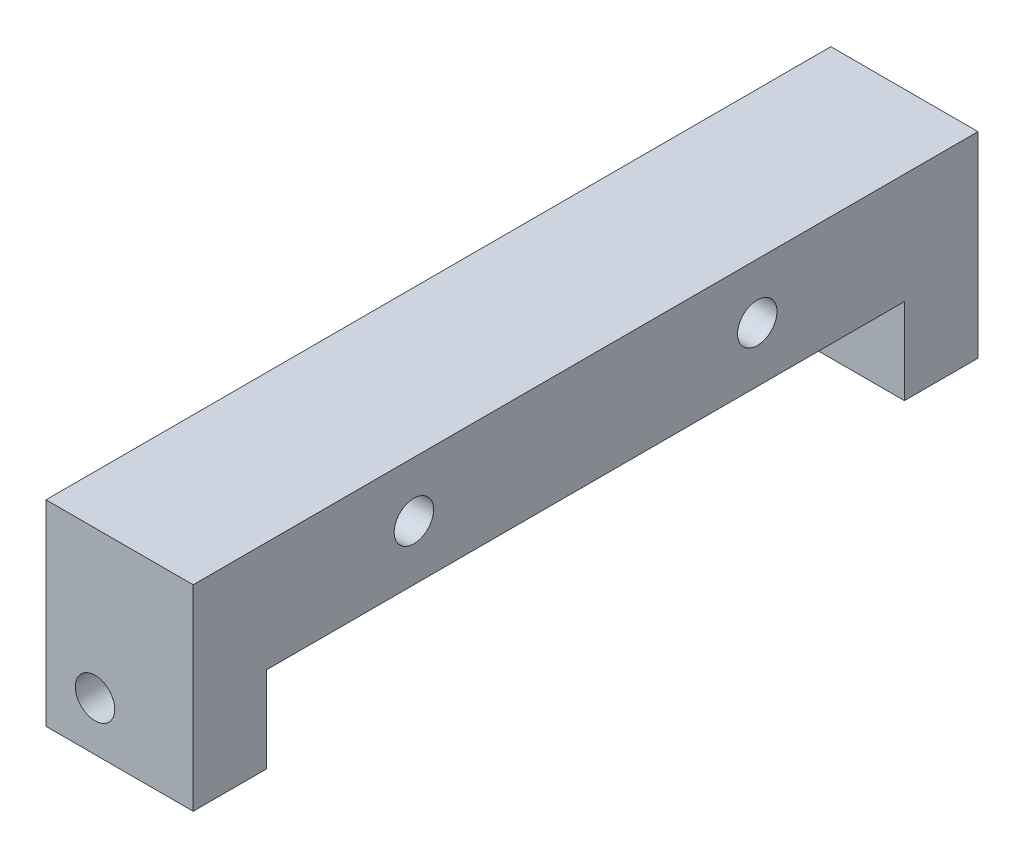
from build123d import *

# Parameters (mm, degrees)
SKETCH1_W                   = 19.05
SKETCH1_H                   = 25.4
EXTRUDE1_DEPTH              = 50.8
CUT_EXTRUDE1_REACH          = 21.05
SKETCH2_W                   = 82.55
SKETCH2_H                   = 11.1125
F_1_4_20_TAPPED_HOLE1_D     = 5.1054
F_1_4_20_TAPPED_HOLE1_DEPTH = 9.525
F_1_4_20_TAPPED_HOLE2_D     = 5.1054
F_1_4_20_TAPPED_HOLE2_DEPTH = 9.525
F_1_4_20_TAPPED_HOLE3_D     = 5.1054
F_1_4_20_TAPPED_HOLE3_DEPTH = 16.51
F_1_4_20_TAPPED_HOLE3_TIP   = 1.533816902
F_1_4_20_TAPPED_HOLE4_D     = 5.1054
F_1_4_20_TAPPED_HOLE4_DEPTH = 19.05


with BuildPart() as part:
    # Sketch1 → Extrude1 (new body, symmetric)
    with BuildSketch(Plane.XY):
        Rectangle(SKETCH1_W, SKETCH1_H)
    extrude(amount=EXTRUDE1_DEPTH, both=True)

    # Sketch2 → Cut-Extrude1 (cut, up to next)
    with BuildSketch(Plane(origin=(9.525, 0, 0), x_dir=(0, 0, -1), z_dir=(1, 0, 0)), mode=Mode.PRIVATE) as cut_extrude1_sk1:
        with Locations((0, -7.14375)):
            Rectangle(SKETCH2_W, SKETCH2_H)
    cut_extrude1_tool1 = extrude(cut_extrude1_sk1.sketch, amount=-CUT_EXTRUDE1_REACH, mode=Mode.PRIVATE) & part.part
    add(cut_extrude1_tool1.solids().sort_by_distance((9.525, -7.14375, 0))[0], mode=Mode.SUBTRACT)

    # 1/4-20 Tapped Hole1
    with Locations(Plane(origin=(0, 0, -50.8), x_dir=(-1, 0, 0), z_dir=(0, 0, -1))):
        with Locations((3.175, -6.35)):
            Hole(F_1_4_20_TAPPED_HOLE1_D / 2, depth=F_1_4_20_TAPPED_HOLE1_DEPTH)

    # 1/4-20 Tapped Hole2
    with Locations(Plane.XY.offset(50.8)):
        with Locations((-3.175, -6.35)):
            Hole(F_1_4_20_TAPPED_HOLE2_D / 2, depth=F_1_4_20_TAPPED_HOLE2_DEPTH)

    # 1/4-20 Tapped Hole3
    with Locations(Plane.XZ.offset(12.7)):
        with Locations((4.7625, 46.0375), (4.7625, -46.0375)):
            Hole(F_1_4_20_TAPPED_HOLE3_D / 2, depth=F_1_4_20_TAPPED_HOLE3_DEPTH)
            with Locations((0, 0, -(F_1_4_20_TAPPED_HOLE3_DEPTH + F_1_4_20_TAPPED_HOLE3_TIP / 2))):  # 118° drill point
                Cone(0, F_1_4_20_TAPPED_HOLE3_D / 2, F_1_4_20_TAPPED_HOLE3_TIP, mode=Mode.SUBTRACT)

    # 1/4-20 Tapped Hole4
    with Locations(Plane.ZY.offset(9.525)):
        with Locations((-22.225, 5.5626), (22.225, 5.5626)):
            Hole(F_1_4_20_TAPPED_HOLE4_D / 2, depth=F_1_4_20_TAPPED_HOLE4_DEPTH)


solid = part.part
